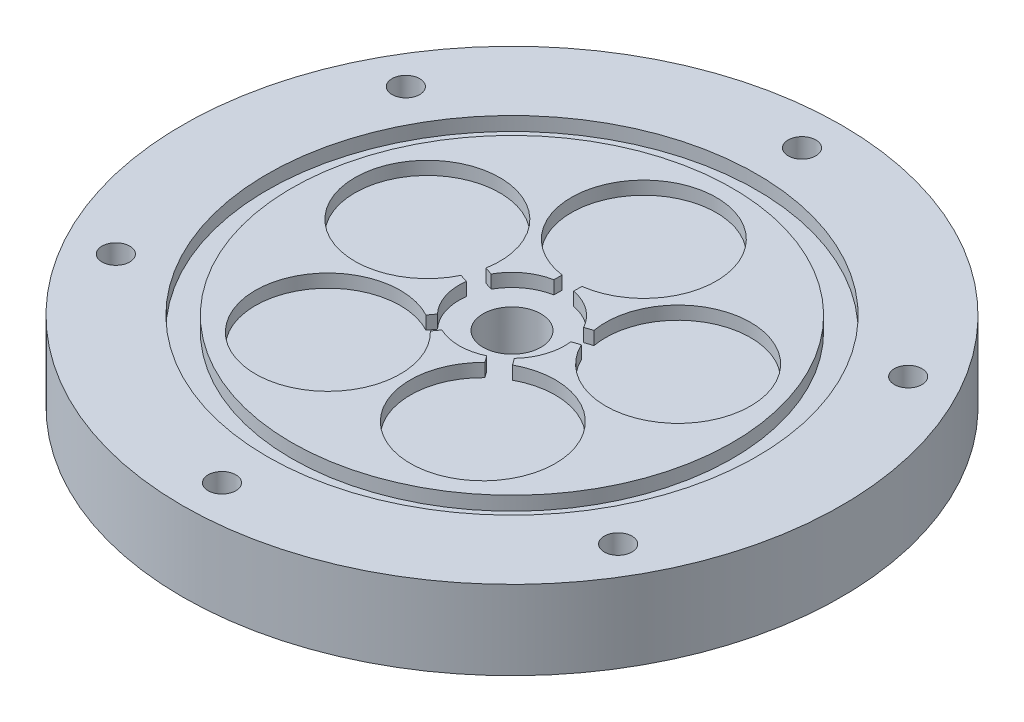
from build123d import *

# Parameters (mm, degrees)
CROQUIS2_R              = 50
SALIENTE_EXTRUIR1_DEPTH = 12
CROQUIS2_3_R            = 11
CORTAR_EXTRUIR1_DEPTH   = 2
CROQUIS2_6_R            = 8
CORTAR_EXTRUIR4_DEPTH   = 2
TALADRO_ROSCADO_G1_81_D = 8.8
CORTAR_EXTRUIR3_DEPTH   = 2
MATRIZC1_COUNT          = 5
CROQUIS7_W              = 3.7
CROQUIS7_H              = 4.2
TALADRO_ROSCADO_M51_D   = 4.2
MATRIZC2_COUNT          = 6


with BuildPart() as part:
    # Croquis2 → Saliente-Extruir1 (new body)
    with BuildSketch(Plane(origin=(0, 0, 0), x_dir=(1, 0, 0), z_dir=(0, 1, 0))):
        Circle(CROQUIS2_R)
    extrude(amount=-SALIENTE_EXTRUIR1_DEPTH)

    # Croquis2_3 → Cortar-Extruir1 (cut)
    with BuildSketch(Plane(origin=(0, 0, 0), x_dir=(1, 0, 0), z_dir=(0, 1, 0))):
        with Locations((0, 20)):
            Circle(CROQUIS2_3_R)
    cortar_extruir1 = extrude(amount=-CORTAR_EXTRUIR1_DEPTH, mode=Mode.SUBTRACT)

    # Croquis2_6 → Cortar-Extruir4 (cut)
    with BuildSketch(Plane(origin=(0, 0, 0), x_dir=(1, 0, 0), z_dir=(0, 1, 0))):
        Circle(CROQUIS2_6_R)
    extrude(amount=-CORTAR_EXTRUIR4_DEPTH, mode=Mode.SUBTRACT)

    # Taladro roscado G1_81 (through all)
    with Locations(Plane(origin=(0, -12, 0), x_dir=(-1, 0, 0), z_dir=(0, -1, 0))):
        with Locations((0, 0)):
            Hole(TALADRO_ROSCADO_G1_81_D / 2)

    # Croquis6 → Cortar-Extruir3 (cut)
    with BuildSketch(Plane(origin=(0, 0, 0), x_dir=(1, 0, 0), z_dir=(0, 1, 0))):
        with BuildLine():
            Line((1.5, 20), (1.5, 0))
            ThreePointArc((1.5, 0), (0, -1.5), (-1.5, 0))
            Line((-1.5, 0), (-1.5, 20))
            ThreePointArc((-1.5, 20), (0, 21.5), (1.5, 20))
        make_face()
    cortar_extruir3 = extrude(amount=-CORTAR_EXTRUIR3_DEPTH, mode=Mode.SUBTRACT)

    # MatrizC1: Cortar-Extruir1, Cortar-Extruir3 ×5 about axis
    matrizc1_axis = Axis((0, 0, 0), (0, 1, 0))
    for i in range(1, MATRIZC1_COUNT):
        add(cortar_extruir1.rotate(matrizc1_axis, i * 360 / MATRIZC1_COUNT), mode=Mode.SUBTRACT)
        add(cortar_extruir3.rotate(matrizc1_axis, i * 360 / MATRIZC1_COUNT), mode=Mode.SUBTRACT)

    # Croquis7 → Cortar-Revolución1 (revolve, cut)
    with BuildSketch(Plane(origin=(0, 0, 0), x_dir=(0, 0, -1), z_dir=(1, 0, 0))):
        with Locations((35.285, 0)):
            Rectangle(CROQUIS7_W, CROQUIS7_H)
    revolve(axis=Axis((0, 0, 0), (0, -1, 0)), mode=Mode.SUBTRACT)

    # Taladro roscado M51 (through all)
    with Locations(Plane(origin=(0, 0, 0), x_dir=(1, 0, 0), z_dir=(0, 1, 0))):
        with Locations((0, 44)):
            taladro_roscado_m51 = Hole(TALADRO_ROSCADO_M51_D / 2)

    # MatrizC2: Taladro roscado M51 ×6 about axis
    matrizc2_axis = Axis((0, 0, 0), (0, 1, 0))
    for i in range(1, MATRIZC2_COUNT):
        add(taladro_roscado_m51.rotate(matrizc2_axis, i * 360 / MATRIZC2_COUNT), mode=Mode.SUBTRACT)


solid = part.part
